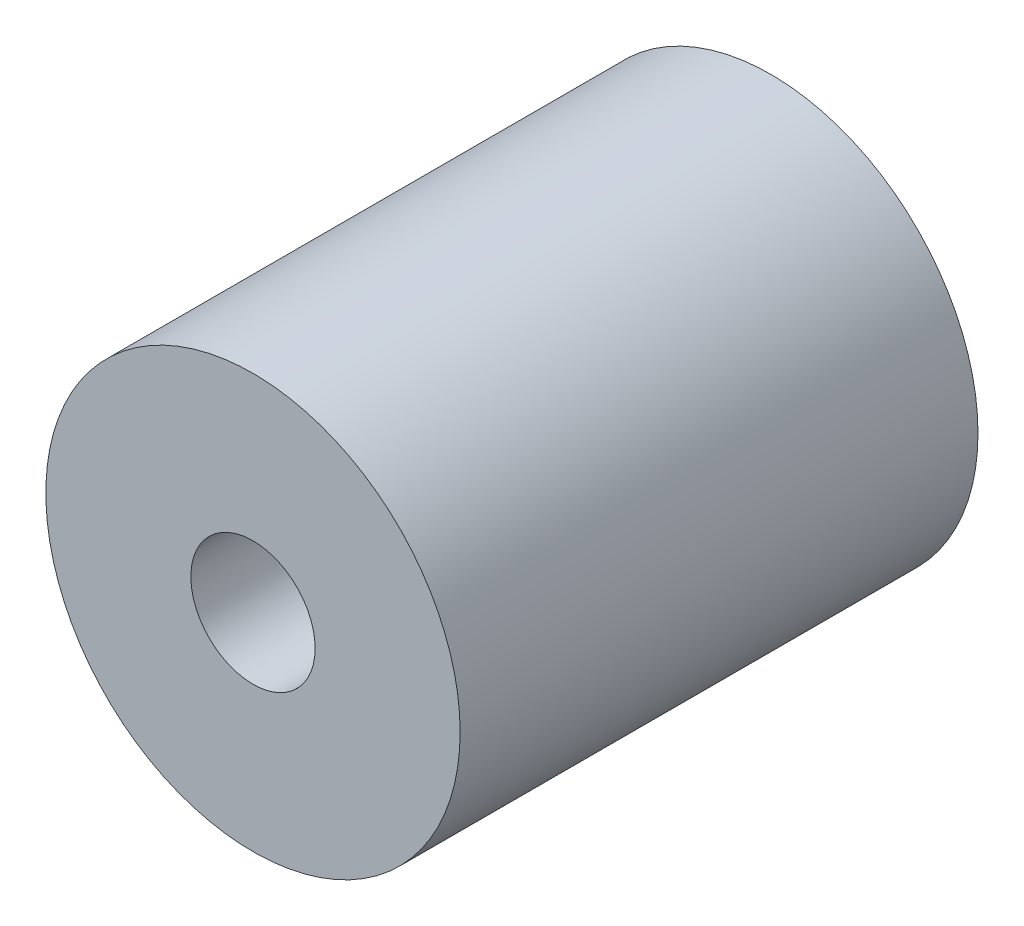
from build123d import *

# Parameters (mm, degrees)
ESQUISSE1_R        = 10
ESQUISSE1_R_2      = 3
BOSS_EXTRU_1_DEPTH = 25


with BuildPart() as part:
    # Esquisse1 → Boss.-Extru.1 (new body)
    with BuildSketch(Plane.XY):
        Circle(ESQUISSE1_R)
        Circle(ESQUISSE1_R_2, mode=Mode.SUBTRACT)
    extrude(amount=BOSS_EXTRU_1_DEPTH)


solid = part.part
